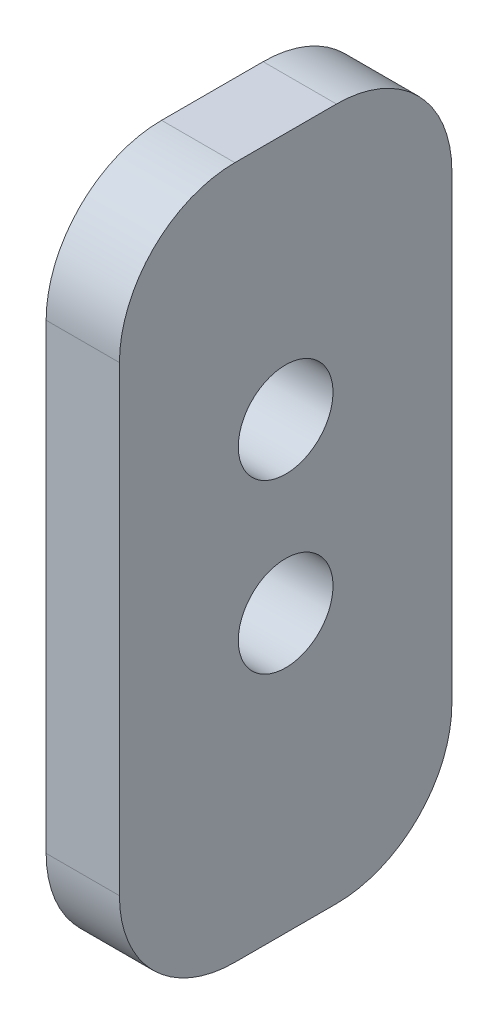
from build123d import *

# Parameters (mm, degrees)
SKETCH1_R                = 4
SKETCH1_W                = 28.8
SKETCH1_H                = 60
BOSS_EXTRUDE1_DEPTH      = 6.35
F_5_16_CLEARANCE_HOLE1_D = 8.2042
FILLET1_R                = 10


with BuildPart() as part:
    # Sketch1 → Boss-Extrude1 (new body)
    with BuildSketch(Plane(origin=(0, 0, 0), x_dir=(0, 0, -1), z_dir=(1, 0, 0))):
        with Locations((0, -6)):
            Circle(SKETCH1_R)
        with Locations((0, 8.53)):
            Circle(SKETCH1_R)
        Rectangle(SKETCH1_W, SKETCH1_H)
        with Locations((0, -6)):
            Circle(SKETCH1_R, mode=Mode.SUBTRACT)
        with Locations((0, 8.53)):
            Circle(SKETCH1_R, mode=Mode.SUBTRACT)
    extrude(amount=BOSS_EXTRUDE1_DEPTH)

    # 5/16 Clearance Hole1 (through all)
    with Locations(Plane.ZY):
        with Locations((0, 8.53), (0, -6)):
            Hole(F_5_16_CLEARANCE_HOLE1_D / 2)

    # Fillet1
    fillet1_edges = [part.edges().sort_by_distance(p)[0] for p in [
        (3.175, 30, 14.4),
        (3.175, 30, -14.4),
        (3.175, -30, -14.4),
        (3.175, -30, 14.4),
    ]]
    fillet(fillet1_edges, radius=FILLET1_R)


solid = part.part
